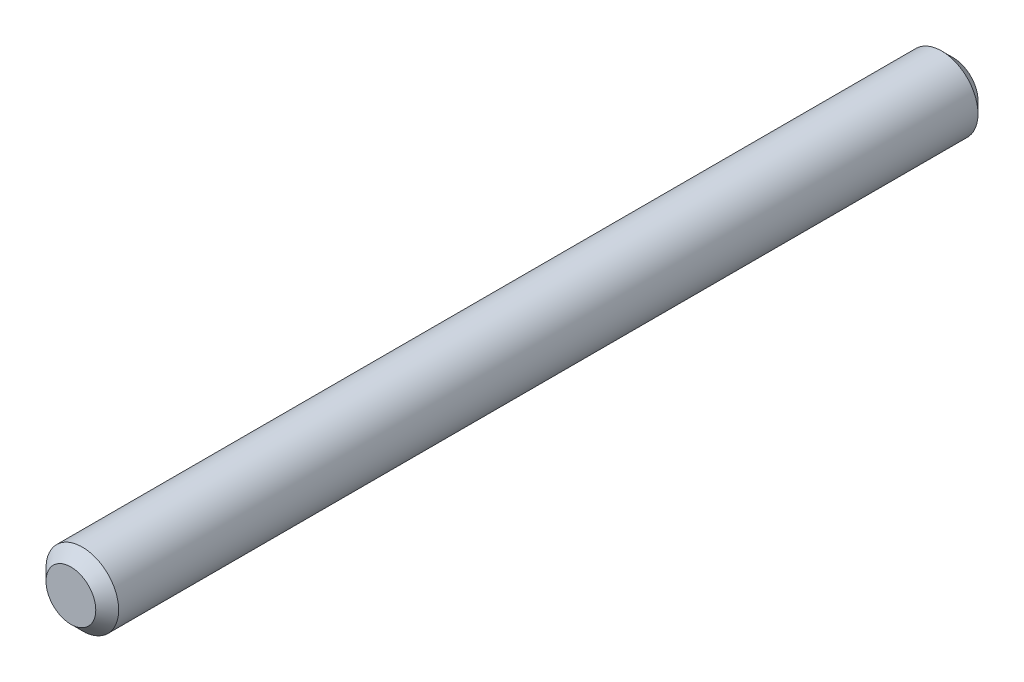
from build123d import *

# Parameters (mm, degrees)
SKETCH1_R           = 3.175
BOSS_EXTRUDE1_DEPTH = 77.086000006
CHAMFER1_SIZE       = 1


with BuildPart() as part:
    # Sketch1 → Boss-Extrude1 (new body)
    with BuildSketch(Plane.XY):
        Circle(SKETCH1_R)
    extrude(amount=-BOSS_EXTRUDE1_DEPTH)

    # Chamfer1
    chamfer1_edges = [part.edges().sort_by_distance(p)[0] for p in [
        (-3.175, 0, 0),
        (-3.175, 0, -77.086000006),
    ]]
    chamfer(chamfer1_edges, length=CHAMFER1_SIZE)


solid = part.part
